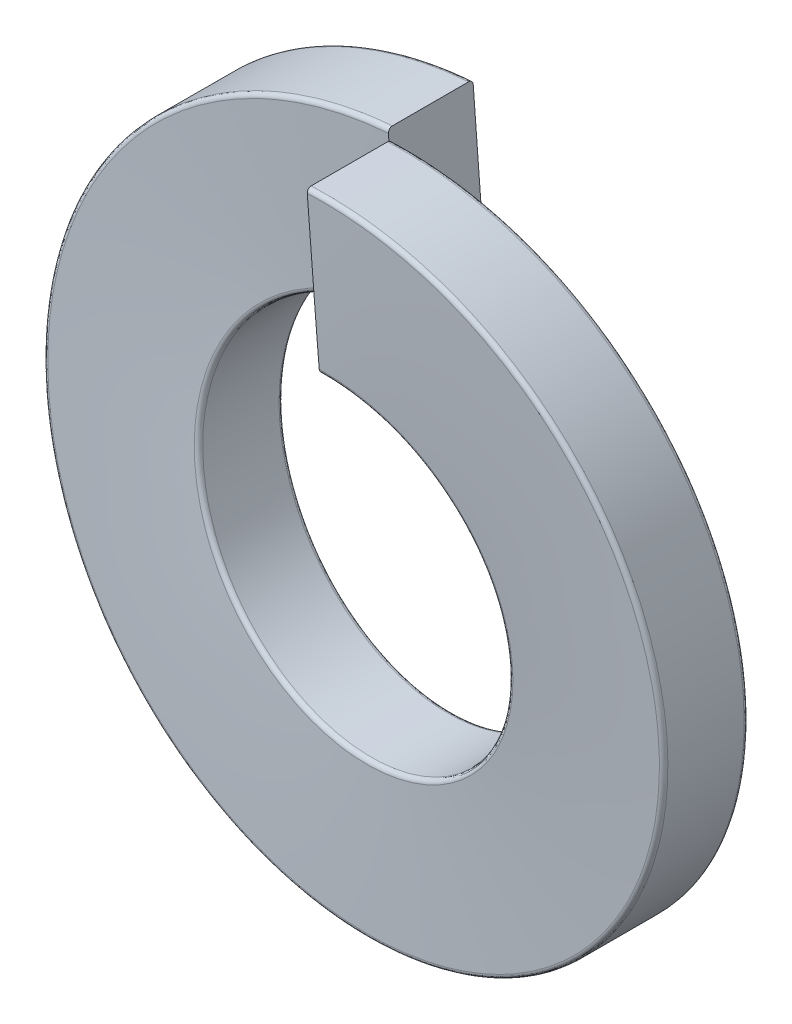
from build123d import *

# Parameters (mm, degrees)
SWEEP1_PITCH            = 1.73228
SWEEP1_HEIGHT           = 1.73228
SWEEP1_RADIUS           = 6.1849
SWEEP1_START_ANGLE      = 90
SKETCH4_W               = 1.5748
SKETCH4_H               = 2.8829
FILLET1_R               = 0.07874
CUT_EXTRUDE1_DEPTH      = 2.5748001
CUT_EXTRUDE1_DEPTH_BACK = 2.7322801


with BuildPart() as part:
    # Sweep1: sweep along a helix
    with BuildLine() as sweep1_path:
        add(Helix(SWEEP1_PITCH, SWEEP1_HEIGHT, SWEEP1_RADIUS, center=(0, 0, -1.73228), direction=(0, 0, 1), mode=Mode.PRIVATE).rotate(Axis((0, 0, -1.73228), (0, 0, 1)), SWEEP1_START_ANGLE))
    # Sketch4 → Sweep1 (sweep)
    with BuildSketch(Plane(origin=(0, 0, 0), x_dir=(0, 0, -1), z_dir=(1, 0, 0))):
        with Locations((0.94488, 4.74345)):
            Rectangle(SKETCH4_W, SKETCH4_H)
    sweep(path=sweep1_path.line, is_frenet=True)

    # Fillet1
    fillet1_edges = [part.edges().sort_by_distance(p)[0] for p in [
        (0, -6.184893342, 0.70866),
        (0, -3.301996445, 0.70866),
        (0, -3.301996445, -0.86614),
        (0, -6.184893341, -0.86614),
    ]]
    fillet(fillet1_edges, radius=FILLET1_R)

    # Sketch5 → Cut-Extrude1 (cut, two sides)
    with BuildSketch(Plane.XY) as cut_extrude1_sk:
        with BuildLine():
            Line((0, 6.1849), (0.216665859, 3.294883899))
            Line((0.216665859, 3.294883899), (0.216665859, 0))
            Line((0.216665859, 0), (0, 0))
            Line((0, 0), (0, 3.302))
            Line((0, 3.302), (-0.215849897, 6.181132326))
            ThreePointArc((-0.215849897, 6.181132326), (-0.107941389, 6.18395801), (0, 6.1849))
        make_face()
    extrude(amount=CUT_EXTRUDE1_DEPTH, mode=Mode.SUBTRACT)
    extrude(cut_extrude1_sk.sketch, amount=-CUT_EXTRUDE1_DEPTH_BACK, mode=Mode.SUBTRACT)


solid = part.part
